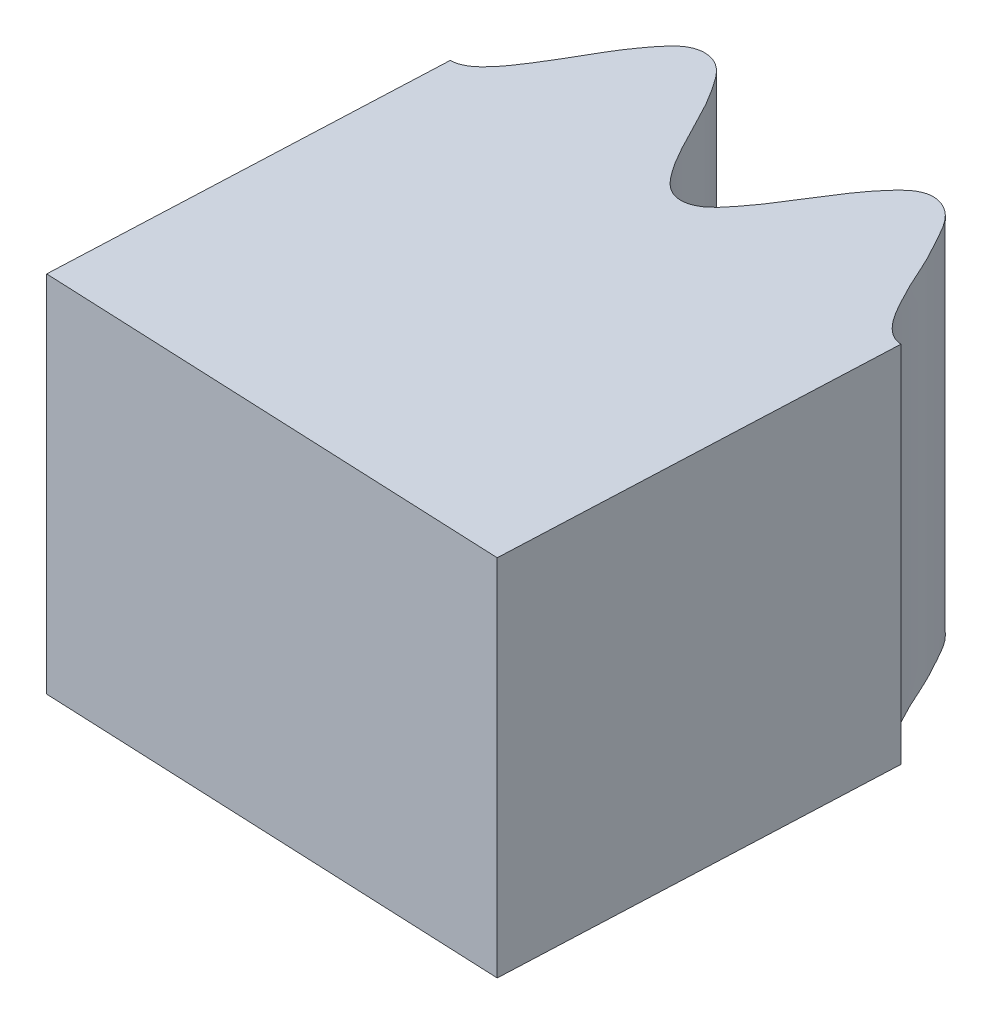
from build123d import *

# Parameters (mm, degrees)
BOSS_EXTRUDE1_DEPTH     = 4
CUT_EXTRUDE1_DEPTH      = 108.175858735
CUT_EXTRUDE1_DEPTH_BACK = 108.175858735
CUT_EXTRUDE2_DEPTH      = 108.175858735
CUT_EXTRUDE2_DEPTH_BACK = 108.175858735
BOSS_EXTRUDE2_DEPTH     = 4


with BuildPart() as part:
    # Sketch1 → Boss-Extrude1 (new body)
    with BuildSketch(Plane(origin=(0, 0, 0), x_dir=(1, 0, 0), z_dir=(0, 1, 0))):
        with BuildLine():
            Line((0, 75), (0, 70))
            ThreePointArc((0, 70), (49.497474683, 49.497474683), (70, 0))
            Line((70, 0), (75, 0))
            add(Edge.make_bspline(
                [(75, 0), (75.050380079, 0.027988933), (75.150135116, 0.083928974), (75.385849219, 0.218346892), (75.556555779, 0.343302659), (75.793115459, 0.559091771), (75.726722821, 0.834487841), (75.524960142, 0.992415461), (75.335000623, 1.121349717), (75.126464936, 1.235293314), (74.920161758, 1.346137726), (74.711717083, 1.454249545), (74.512091935, 1.582315518), (74.31519481, 1.710306134), (74.163925882, 1.951349773), (74.330026374, 2.215393011), (74.573477976, 2.375635279), (74.836790459, 2.557091933), (75.141374934, 2.718012309), (75.389801527, 2.903502283), (75.648009918, 3.082166594), (75.723439753, 3.396877772), (75.484714529, 3.607987744), (75.257107431, 3.741829311), (75.004765702, 3.881288724), (74.700478181, 4.006189191), (74.467832583, 4.166559633), (74.081283762, 4.334614415), (74.09284664, 4.763739624), (74.445000666, 4.953113102), (74.663168002, 5.151438188), (74.94910869, 5.304380051), (75.178477729, 5.481747085), (75.393823876, 5.637930813), (75.582039215, 5.900063188), (75.423263936, 6.184063895), (75.153916827, 6.321420138), (74.878763729, 6.475334049), (74.5559891, 6.595691699), (74.279522738, 6.747645077), (74.008187432, 6.878454168), (73.839963794, 7.158428572), (74.030263913, 7.423041671), (74.237833878, 7.581836742), (74.470150707, 7.766479023), (74.737154867, 7.928082807), (74.970020459, 8.1380106), (75.252496752, 8.326816283), (75.307893073, 8.683144239), (75.032251257, 8.866746013), (74.82784501, 8.980258245), (74.580383895, 9.083638758), (74.349881421, 9.178011902), (74.104661365, 9.274265746), (73.887987065, 9.389698553), (73.645710544, 9.521815238), (73.566612993, 9.80014415), (73.759151351, 10.018596352), (73.934367827, 10.182293625), (74.145907118, 10.343780146), (74.341023974, 10.49346119), (74.561479221, 10.654271157), (74.72121168, 10.816376575), (74.989223643, 11.059535394), (74.862651988, 11.461920806), (74.451242671, 11.561758423), (74.15694857, 11.722473713), (73.81648944, 11.813693993), (73.579175892, 11.938444947), (73.300383285, 12.049406982), (73.16438962, 12.33940789), (73.364023484, 12.589425786), (73.543848199, 12.763957193), (73.760572421, 12.94384802), (73.966599088, 13.108018933), (74.180853477, 13.288597269), (74.360831943, 13.46820344), (74.539613211, 13.708707239), (74.43371274, 13.973785573), (74.203670067, 14.090873366), (73.996553795, 14.186713105), (73.770279808, 14.261834472), (73.548334678, 14.335540611), (73.324103361, 14.405672823), (73.105333431, 14.497176402), (72.88918309, 14.589016669), (72.698363493, 14.800137022), (72.816085622, 15.089008525), (73.028015684, 15.289093489), (73.255816396, 15.513515693), (73.527831137, 15.724882744), (73.740272942, 15.950693037), (73.96353415, 16.171480699), (73.983168867, 16.494508845), (73.711411643, 16.660957453), (73.464021005, 16.753242061), (73.191296074, 16.846764116), (72.869942608, 16.916928077), (72.612983394, 17.034463655), (72.203124707, 17.132841805), (72.13999511, 17.557455513), (72.453914764, 17.805102886), (72.63432886, 18.038299329), (72.88936739, 18.238570741), (73.084452336, 18.453072687), (73.269405871, 18.644278099), (73.409242987, 18.935111345), (73.203563656, 19.187226405), (72.914456873, 19.275724264), (72.616757098, 19.379520042), (72.277986255, 19.441999963), (71.979333611, 19.543636947), (71.689405738, 19.625341873), (71.47512075, 19.871851109), (71.6165802, 20.165489409), (71.793422236, 20.357916172), (71.990146855, 20.580094717), (72.225032419, 20.785608162), (72.417906681, 21.032783366), (72.663305761, 21.26777216), (72.655984788, 21.628306163), (72.352648477, 21.761253914), (72.131636428, 21.837546868), (71.869982965, 21.896385627), (71.626594617, 21.949298697), (71.368385701, 22.001508213), (71.134958474, 22.077562239), (70.873420856, 22.165600898), (70.747193666, 22.425966223), (70.898873107, 22.67453358), (71.043001918, 22.866169945), (71.223285612, 23.061936536), (71.389446363, 23.243225275), (71.578628043, 23.439873829), (71.707784496, 23.627253752), (71.929500669, 23.913258231), (71.734978429, 24.287551568), (71.312482723, 24.314431948), (70.994751694, 24.421601978), (70.643624667, 24.452316309), (70.388253669, 24.533962951), (70.094428194, 24.594827395), (69.910142448, 24.856807486), (70.063328273, 25.137693104), (70.210113987, 25.340799221), (70.392307966, 25.555590868), (70.566696646, 25.753043812), (70.74633893, 25.968083641), (70.892394834, 26.176214124), (71.026696966, 26.444109171), (70.876374992, 26.686770946), (70.629495102, 26.76213342), (70.408882995, 26.820551776), (70.173001931, 26.855239815), (69.941629709, 26.889285824), (69.708626639, 26.919415211), (69.477290886, 26.971539645), (69.248476459, 27.024450539), (69.023895176, 27.199228025), (69.089666831, 27.504153154), (69.26363281, 27.737999647), (69.449002211, 27.998569552), (69.680180933, 28.253960326), (69.850183724, 28.513230186), (70.031713718, 28.769432489), (69.99495689, 29.090962644), (69.698424772, 29.207692377), (69.438767499, 29.255616041), (69.153945938, 29.300359099), (68.82529071, 29.313654668), (68.551825444, 29.384784117), (68.131110245, 29.410496468), (67.995206332, 29.817697), (68.261353327, 30.116093629), (68.398532389, 30.377075873), (68.614919545, 30.618591688), (68.769792841, 30.863711013), (68.918734044, 31.084128429), (69.005944057, 31.394825725), (68.759610136, 31.60739475), (68.459528044, 31.644345262), (68.14832705, 31.694869125), (67.803853373, 31.697572897), (67.492088856, 31.745805299), (67.192377728, 31.775923497), (66.93854233, 31.981477506), (67.026862937, 32.295218956), (67.167603789, 32.515430621), (67.32275882, 32.768394646), (67.518388909, 33.01157333), (67.665411453, 33.288485652), (67.866276995, 33.562517541), (67.79646117, 33.916302949), (67.474647085, 33.994557128), (67.243744573, 34.03131268), (66.975848971, 34.0438219), (66.726969981, 34.053667158), (66.463617751, 34.060245986), (66.220530165, 34.094610368), (65.947678138, 34.135895991), (65.778156659, 34.37038666), (65.88436848, 34.641516579), (65.993030345, 34.855269263), (66.136580612, 35.079367654), (66.26873655, 35.286755721), (66.420896471, 35.513267796), (66.515552566, 35.720228779), (66.684236215, 36.040388818), (66.427673849, 36.375217365), (66.006929074, 36.328323763), (65.675415212, 36.378692224), (65.324289106, 36.347967367), (65.058619977, 36.384028905), (64.758689371, 36.392946423), (64.531710975, 36.618945564), (64.633794287, 36.922164338), (64.743080989, 37.147673888), (64.885208854, 37.39084002), (65.022660834, 37.615575486), (65.162232674, 37.858542932), (65.269928182, 38.088873787), (65.355670476, 38.376020227), (65.165494455, 38.588892287), (64.909278669, 38.620239594), (64.681873915, 38.639461552), (64.443552899, 38.632662285), (64.209783714, 38.626013695), (63.975088571, 38.61522479), (63.738216014, 38.626386305), (63.503689913, 38.638760155), (63.252170732, 38.771884247), (63.263993475, 39.083598007), (63.394709502, 39.344100721), (63.532015236, 39.632901042), (63.715333692, 39.924555621), (63.83773202, 40.209407264), (63.972015102, 40.493239631), (63.879983568, 40.803502265), (63.567686533, 40.866966348), (63.30365218, 40.869072932), (63.015388149, 40.863677497), (62.68941718, 40.819700696), (62.407754967, 40.842262783), (61.988966475, 40.794528078), (61.784417618, 41.171942853), (61.99470521, 41.512022106), (62.084481123, 41.792860338), (62.255642091, 42.06828222), (62.365597989, 42.336571098), (62.474001359, 42.579503247), (62.505934436, 42.900624212), (62.226430657, 43.0671884), (61.924491097, 43.051468841), (61.609244568, 43.047185648), (61.269534715, 42.990031117), (60.954131133, 42.983393421), (60.653743321, 42.961009764), (60.368070174, 43.119362892), (60.400568362, 43.443674617), (60.500931689, 43.684980165), (60.609802825, 43.961043486), (60.760233318, 44.234498548), (60.856936939, 44.532734146), (61.007165744, 44.83748281), (60.876976387, 45.173770032), (60.546462685, 45.194952924), (60.312685567, 45.191054278), (60.046687698, 45.15685387), (59.799880128, 45.123332174), (59.539386408, 45.08408042), (59.294024556, 45.075711013), (59.018148592, 45.068989158), (58.810483647, 45.270480291), (58.868000656, 45.555934626), (58.937893939, 45.785308862), (59.040349078, 46.030929937), (59.13448471, 46.258115951), (59.244999571, 46.507609091), (59.302279229, 46.727862731), (59.412804987, 47.072450427), (59.101998013, 47.357640589), (58.695788285, 47.238397843), (58.360564473, 47.230434316), (58.020108077, 47.13920383), (57.752213038, 47.128584552), (57.455290541, 47.08528419), (57.192516118, 47.268435511), (57.240395168, 47.584774291), (57.308862236, 47.825835282), (57.406605504, 48.089987418), (57.502944375, 48.335176934), (57.598204951, 48.598689554), (57.664267789, 48.844222294), (57.698845009, 49.141895328), (57.474593344, 49.318509663), (57.216826649, 49.304889329), (56.989538826, 49.284330842), (56.756019122, 49.236250861), (56.526955932, 49.189109685), (56.297699809, 49.137730304), (56.062487702, 49.107589762), (55.829375882, 49.079050596), (55.558561088, 49.166476387), (55.51607569, 49.475507512), (55.599570026, 49.754751204), (55.684640127, 50.06300689), (55.814528278, 50.382063496), (55.885603131, 50.683841849), (55.968559178, 50.986680177), (55.824049269, 51.276248116), (55.505476305, 51.284518227), (55.245087423, 51.240743723), (54.962139678, 51.185373733), (54.648757432, 51.085460773), (54.367456436, 51.058769962), (53.963319326, 50.939038596), (53.696340638, 51.275200055), (53.844379347, 51.646628798), (53.884024315, 51.93878989), (54.004758455, 52.239749285), (54.066456001, 52.523055893), (54.131027755, 52.781121404), (54.106713627, 53.102908941), (53.802532571, 53.218407323), (53.507909823, 53.150495326), (53.198196367, 53.091535218), (52.87357225, 52.976258997), (52.564112981, 52.914952884), (52.272175616, 52.84074749), (51.963344753, 52.947088254), (51.939033082, 53.272116211), (51.995969392, 53.527183684), (52.055248646, 53.817958278), (52.155908772, 54.113380885), (52.199355211, 54.423878093), (52.294382606, 54.75008379), (52.107775521, 55.058655064), (51.778604574, 55.022122758), (51.549056364, 54.977689105), (51.293037634, 54.897816359), (51.055802482, 54.821950619), (50.806078132, 54.738051344), (50.56590552, 54.687221821), (50.295372778, 54.632661313), (50.055902112, 54.795095863), (50.062915856, 55.08605942), (50.09207674, 55.324458468), (50.149925898, 55.583211719), (50.204091553, 55.825415688), (50.267685365, 56.08583746), (50.289340345, 56.320833048), (50.33220459, 56.665051109), (50.043864784, 56.879773011), (49.725988748, 56.758235804), (49.458556625, 56.70381228), (49.208859877, 56.602430564), (48.958192708, 56.510209672), (48.688345013, 56.434892178), (48.407243163, 56.349527164), (48.114974261, 56.48034264), (48.108115299, 56.802336912), (48.13315996, 57.050406823), (48.183821075, 57.328153727), (48.235988604, 57.586041862), (48.284103231, 57.862232281), (48.306500727, 58.115447335), (48.288872371, 58.414625886), (48.037354269, 58.549605515), (47.785871198, 58.491437036), (47.565604998, 58.431719652), (47.343982615, 58.343821314), (47.126585124, 58.257619294), (46.909733953, 58.167210809), (46.683329063, 58.096683937), (46.45871452, 58.028098927), (46.176832677, 58.067170017), (46.081330039, 58.364128759), (46.115065748, 58.653628748), (46.145315407, 58.971973608), (46.217826665, 59.308737866), (46.235418471, 59.618273548), (46.264526906, 59.930916246), (46.071929482, 60.190991116), (45.756760267, 60.14381597), (45.507928641, 60.055490445), (45.238894405, 59.951828289), (44.947622843, 59.799014975), (44.675230252, 59.723882252), (44.298024026, 59.535792202), (43.976727519, 59.820486251), (44.058019263, 60.211978809), (44.046328694, 60.506585594), (44.112967561, 60.823938002), (44.124532107, 61.113654213), (44.143310265, 61.379011896), (44.063487703, 61.691688654), (43.743871757, 61.752611869), (43.465517786, 61.634570905), (43.170747888, 61.522725356), (42.871073047, 61.352830054), (42.576960853, 61.238718279), (42.302344305, 61.114945843), (41.979739396, 61.166043132), (41.899356564, 61.481911513), (41.911135875, 61.742990809), (41.919022081, 62.039641651), (41.966853329, 62.348055511), (41.955722493, 62.661380074), (41.992661108, 62.999131137), (41.755306272, 63.270610783), (41.437479747, 63.177473111), (41.21913522, 63.093855031), (40.98087445, 62.970735598), (40.760420405, 62.854833848), (40.529052255, 62.72882995), (40.30136826, 62.637097556), (40.044395352, 62.536332758), (39.780401399, 62.65481835), (39.736685168, 62.942356463), (39.724263543, 63.182783839), (39.735658003, 63.446188529), (39.748425967, 63.697489546), (39.762655618, 63.957780496), (39.749210432, 64.206680433), (39.725416869, 64.467041136), (39.536087518, 64.660427871), (39.277015035, 64.613902502), (39.074812109, 64.531265857), (38.854985285, 64.417855901), (38.635555446, 64.29480726), (38.399826184, 64.149361027), (38.149659321, 64.034015597), (37.886507528, 63.898535171), (37.576462819, 63.977747086), (37.513522678, 64.293041196), (37.4952636, 64.542040428), (37.496844849, 64.824183237), (37.503476484, 65.087299643), (37.502882645, 65.367609285), (37.480976988, 65.620883641), (37.41166167, 65.912449127), (37.140527066, 66.001705495), (36.902964728, 65.900749534), (36.696415072, 65.803691456), (36.493422833, 65.678643748), (36.294296999, 65.556000829), (36.096439524, 65.429309974), (35.885721106, 65.32053979), (35.676428622, 65.213992827), (35.392044574, 65.203522074), (35.246426491, 65.479385485), (35.229378534, 65.770345464), (35.203888627, 66.089106747), (35.216819777, 66.433346248), (35.180394017, 66.741234172), (35.154770394, 67.054181752), (34.919937431, 67.276861308), (34.617748223, 67.1756743), (34.388034474, 67.045481479), (34.141088217, 66.896676879), (33.880777479, 66.695606367), (33.625569803, 66.574314602), (33.286755682, 66.323580888), (32.920903788, 66.548157242), (32.932978559, 66.947818312), (32.870307664, 67.235919312), (32.88082647, 67.560022142), (32.841906632, 67.847345074), (32.814320629, 68.111932171), (32.681415003, 68.405997624), (32.356075536, 68.410494553), (32.102447986, 68.245911235), (31.83157808, 68.084578617), (31.565957983, 67.865226415), (31.296129317, 67.70177621), (31.047177668, 67.532197488), (30.720600902, 67.526498746), (30.586589296, 67.823610033), (30.552853713, 68.082768431), (30.509107222, 68.376281848), (30.502656319, 68.688316125), (30.437286313, 68.99494754), (30.415013942, 69.333982027), (30.134123041, 69.560120626), (29.837298333, 69.413208698), (29.636790733, 69.292943812), (29.423530024, 69.130326456), (29.226549247, 68.97789203), (29.020580945, 68.813652154), (28.812276052, 68.683723109), (28.576721385, 68.53996383), (28.296132702, 68.610627797), (28.203216725, 68.886597007), (28.149058966, 69.120187564), (28.114977181, 69.384129224), (28.082908023, 69.6279459), (28.05387013, 69.899270728), (27.993348949, 70.118655804), (27.916773216, 70.472340382), (27.5050114, 70.56391882), (27.212844829, 70.257546708), (26.926514255, 70.083038186), (26.67728561, 69.83380207), (26.45059134, 69.690657985), (26.215099096, 69.504697523), (25.895954109, 69.531924008), (25.779249192, 69.829820953), (25.718012918, 70.072819429), (25.670585003, 70.350453524), (25.631422155, 70.610963309), (25.582163923, 70.88680222), (25.516609649, 71.132471229), (25.397717883, 71.407552249), (25.115203076, 71.448378917), (24.898780737, 71.307700015), (24.712222952, 71.176251931), (24.534028947, 71.017853594), (24.359224993, 70.862496543), (24.186373057, 70.703372632), (23.997743668, 70.559664104), (23.810132494, 70.418392551), (23.531887106, 70.358698109), (23.34057811, 70.605084216), (23.27326448, 70.888663515), (23.192809506, 71.19815582), (23.145767641, 71.539411021), (23.056431093, 71.836296169), (22.976853973, 72.140039877), (22.706920751, 72.318558114), (22.426893416, 72.166433758), (22.223277282, 71.998329485), (22.005922341, 71.808903794), (21.784481835, 71.56568551), (21.554213432, 71.401920091), (21.264086111, 71.096161131), (20.864795055, 71.253796151), (20.807285966, 71.649482233), (20.69553897, 71.922323644), (20.649618105, 72.243329196), (20.561396443, 72.519528688), (20.488284467, 72.775305854), (20.306334046, 73.041824972), (19.985156333, 72.989758976), (19.763961548, 72.783634087), (19.52522188, 72.577716409), (19.301727259, 72.315572213), (19.064380727, 72.107749928), (18.848658249, 71.897517488), (18.528032494, 71.835195863), (18.344463992, 72.10452249), (18.266238545, 72.353885567), (18.172188591, 72.635343357), (18.111651508, 72.941516945), (17.994028633, 73.232138557), (17.913221909, 73.562154792), (17.597329816, 73.736081645), (17.330525531, 73.539858569), (17.15394787, 73.386602997), (16.972165278, 73.189423831), (16.804647042, 73.005099874), (16.630327816, 72.80758915), (16.447749484, 72.643462255), (16.24073696, 72.460983363), (15.95214038, 72.481850072), (15.812714454, 72.737492), (15.718816899, 72.958129395), (15.639419905, 73.212142949), (15.565499628, 73.44668675), (15.489787824, 73.708847167), (15.392090277, 73.914389898), (15.255261219, 74.249403976), (14.833852561, 74.268089443), (14.599325616, 73.91563762), (14.347648133, 73.694059491), (14.145485229, 73.405331732), (13.947091664, 73.224997281), (13.747468771, 73.000969177), (13.428444485, 72.972363085), (13.261783316, 73.24546871), (13.159281115, 73.474141926), (13.064363082, 73.739322364), (12.980558157, 73.989073862), (12.884149344, 74.252168559), (12.776931011, 74.482721923), (12.612078161, 74.732978505), (12.326765912, 74.724126744), (12.138060149, 74.548003725), (11.977162316, 74.386157214), (11.829181061, 74.199222239), (11.684010241, 74.015871023), (11.541415892, 73.829149138), (11.380606931, 73.654868716), (11.220377539, 73.483165057), (10.956725155, 73.376060703), (10.725538075, 73.585483192), (10.610004061, 73.853065395), (10.477028604, 74.143884958), (10.371443067, 74.471786991), (10.231910177, 74.748648657), (10.100797471, 75.033959394), (9.803965775, 75.162892126), (9.554608801, 74.964452645), (9.383277054, 74.763544682), (9.202117649, 74.539253504), (9.026275734, 74.261277511), (8.827943192, 74.060014369), (8.595318043, 73.708520494), (8.174720081, 73.79442452), (8.049374518, 74.174112892), (7.891946796, 74.423404568), (7.790981543, 74.731559249), (7.656138628, 74.98824312), (7.539722148, 75.227438694), (7.314255404, 75.458313428), (7.006998267, 75.351266508), (6.824957139, 75.109863048), (6.625601693, 74.865617013), (6.451023319, 74.568645944), (6.253370576, 74.322766152), (6.077431887, 74.078267803), (5.772499195, 73.9612169), (5.54495143, 74.194575524), (5.424612966, 74.426566488), (5.283117197, 74.687416743), (5.170333346, 74.978426629), (5.004031473, 75.244208198), (4.867145729, 75.555178575), (4.525850576, 75.671609329), (4.297173589, 75.432036653), (4.149890663, 75.250448544), (4.005110652, 75.024694787), (3.872142368, 74.814091142), (3.734774401, 74.589290548), (3.5834589, 74.395993722), (3.41129911, 74.18026478), (3.123425549, 74.150838141), (2.941808652, 74.378085029), (2.810807208, 74.579854394), (2.689048386, 74.81425693), (2.574280945, 75.036906087), (2.456832031, 75.272410252), (2.320029139, 75.475394151), (2.159305224, 75.715332045), (1.844035288, 75.763483705), (1.634313572, 75.499980528), (1.47304379, 75.277275417), (1.32422083, 75.014662596), (1.195027528, 74.788052405), (1.052689935, 74.564712631), (0.920118974, 74.378992231), (0.710817146, 74.201954221), (0.456909161, 74.28184324), (0.30476885, 74.498176728), (0.185042825, 74.663213522), (0.074352375, 74.865858994), (0.024779937, 74.955396113), (0, 75)],
                knots=[0.075900432, 0.075900432, 0.075900432, 0.075900432, 0.075900432, 0.077143219, 0.078386005, 0.079628792, 0.080871578, 0.081946406, 0.083021233, 0.08409606, 0.085170887, 0.086245458, 0.087320029, 0.088394601, 0.089469172, 0.090645937, 0.091822703, 0.093374384, 0.094926065, 0.096477746, 0.098029428, 0.099205995, 0.100382563, 0.101707425, 0.103032287, 0.104357149, 0.105682011, 0.10733155, 0.108981089, 0.110629316, 0.112277542, 0.113603053, 0.114928563, 0.116254074, 0.117579584, 0.118755852, 0.11993212, 0.12148425, 0.12303638, 0.124588511, 0.126140641, 0.12731548, 0.128490319, 0.129816645, 0.131142972, 0.132469298, 0.133795624, 0.135443357, 0.137091089, 0.138262925, 0.13943476, 0.140606595, 0.141778431, 0.142949907, 0.144121384, 0.145292861, 0.146464337, 0.147635476, 0.148806615, 0.149977754, 0.151148893, 0.152319617, 0.153490341, 0.154661065, 0.155831789, 0.157914479, 0.15999717, 0.161299161, 0.162601152, 0.163903143, 0.165205135, 0.166443951, 0.167682767, 0.168921584, 0.1701604, 0.171399276, 0.172638153, 0.173877029, 0.175115905, 0.176190732, 0.177265559, 0.178340387, 0.179415214, 0.180489785, 0.181564356, 0.182638927, 0.183713499, 0.184890264, 0.18606703, 0.187618711, 0.189170392, 0.190722073, 0.192273754, 0.193450322, 0.19462689, 0.195951752, 0.197276614, 0.198601476, 0.199926338, 0.201575877, 0.203225416, 0.204873642, 0.206521869, 0.207847379, 0.20917289, 0.2104984, 0.211823911, 0.213000179, 0.214176447, 0.215728577, 0.217280707, 0.218832837, 0.220384968, 0.221559807, 0.222734645, 0.224060972, 0.225387298, 0.226713625, 0.228039951, 0.229687684, 0.231335416, 0.232507252, 0.233679087, 0.234850922, 0.236022758, 0.237194234, 0.238365711, 0.239537188, 0.240708664, 0.241879803, 0.243050942, 0.244222081, 0.24539322, 0.246563944, 0.247734668, 0.248905392, 0.250076115, 0.252158806, 0.254241497, 0.255543488, 0.256845479, 0.25814747, 0.259449461, 0.260688278, 0.261927094, 0.26316591, 0.264404727, 0.265643603, 0.266882479, 0.268121356, 0.269360232, 0.270435059, 0.271509886, 0.272584713, 0.273659541, 0.274734112, 0.275808683, 0.276883254, 0.277957825, 0.279134591, 0.280311356, 0.281863038, 0.283414719, 0.2849664, 0.286518081, 0.287694649, 0.288871217, 0.290196078, 0.29152094, 0.292845802, 0.294170664, 0.295820204, 0.297469743, 0.299117969, 0.300766196, 0.302091706, 0.303417217, 0.304742727, 0.306068238, 0.307244506, 0.308420773, 0.309972904, 0.311525034, 0.313077164, 0.314629294, 0.315804133, 0.316978972, 0.318305299, 0.319631625, 0.320957951, 0.322284278, 0.32393201, 0.325579743, 0.326751578, 0.327923414, 0.329095249, 0.330267084, 0.331438561, 0.332610038, 0.333781514, 0.334952991, 0.33612413, 0.337295269, 0.338466408, 0.339637547, 0.340808271, 0.341978995, 0.343149718, 0.344320442, 0.346403133, 0.348485823, 0.349787815, 0.351089806, 0.352391797, 0.353693788, 0.354932604, 0.356171421, 0.357410237, 0.358649053, 0.35988793, 0.361126806, 0.362365682, 0.363604559, 0.364679386, 0.365754213, 0.36682904, 0.367903867, 0.368978439, 0.37005301, 0.371127581, 0.372202152, 0.373378918, 0.374555683, 0.376107364, 0.377659046, 0.379210727, 0.380762408, 0.381938976, 0.383115543, 0.384440405, 0.385765267, 0.387090129, 0.388414991, 0.39006453, 0.391714069, 0.393362296, 0.395010522, 0.396336033, 0.397661543, 0.398987054, 0.400312564, 0.401488832, 0.4026651, 0.40421723, 0.405769361, 0.407321491, 0.408873621, 0.41004846, 0.411223299, 0.412549625, 0.413875952, 0.415202278, 0.416528605, 0.418176337, 0.41982407, 0.420995905, 0.42216774, 0.423339576, 0.424511411, 0.425682888, 0.426854364, 0.428025841, 0.429197318, 0.430368457, 0.431539596, 0.432710735, 0.433881874, 0.435052597, 0.436223321, 0.437394045, 0.438564769, 0.44064746, 0.44273015, 0.444032141, 0.445334132, 0.446636124, 0.447938115, 0.449176931, 0.450415748, 0.451654564, 0.45289338, 0.454132256, 0.455371133, 0.456610009, 0.457848885, 0.458923713, 0.45999854, 0.461073367, 0.462148194, 0.463222765, 0.464297337, 0.465371908, 0.466446479, 0.467623244, 0.46880001, 0.470351691, 0.471903372, 0.473455053, 0.475006735, 0.476183302, 0.47735987, 0.478684732, 0.480009594, 0.481334456, 0.482659318, 0.484308857, 0.485958396, 0.487606623, 0.489254849, 0.49058036, 0.49190587, 0.493231381, 0.494556891, 0.495733159, 0.496909427, 0.498461557, 0.500013687, 0.501565818, 0.503117948, 0.504292787, 0.505467626, 0.506793952, 0.508120279, 0.509446605, 0.510772931, 0.512420664, 0.514068396, 0.515240232, 0.516412067, 0.517583902, 0.518755738, 0.519927214, 0.521098691, 0.522270168, 0.523441644, 0.524612783, 0.525783922, 0.526955061, 0.5281262, 0.529296924, 0.530467648, 0.531638372, 0.532809096, 0.534891786, 0.535933132, 0.536974477, 0.538276468, 0.539578459, 0.54088045, 0.542182442, 0.543421258, 0.544660074, 0.545898891, 0.547137707, 0.548376583, 0.54961546, 0.550854336, 0.552093212, 0.553168039, 0.554242867, 0.555317694, 0.556392521, 0.557467092, 0.558541663, 0.559616234, 0.560690806, 0.561867571, 0.563044337, 0.564596018, 0.566147699, 0.56769938, 0.569251061, 0.570427629, 0.571604197, 0.572929059, 0.574253921, 0.575578783, 0.576903645, 0.578553184, 0.580202723, 0.581850949, 0.583499176, 0.584824686, 0.586150197, 0.587475707, 0.588801218, 0.589977486, 0.591153754, 0.592705884, 0.594258014, 0.595810144, 0.597362275, 0.598537114, 0.599711952, 0.601038279, 0.602364605, 0.603690932, 0.605017258, 0.606664991, 0.608312723, 0.609484559, 0.610656394, 0.611828229, 0.613000065, 0.614171541, 0.615343018, 0.616514495, 0.617685971, 0.61885711, 0.620028249, 0.621199388, 0.622370527, 0.623541251, 0.624711975, 0.625882699, 0.627053422, 0.628094768, 0.629136113, 0.630177458, 0.631218804, 0.632520795, 0.633822786, 0.635124777, 0.636426768, 0.637665585, 0.638904401, 0.640143217, 0.641382034, 0.64262091, 0.643859786, 0.645098663, 0.646337539, 0.647412366, 0.648487193, 0.64956202, 0.650636848, 0.651711419, 0.65278599, 0.653860561, 0.654935132, 0.656111898, 0.657288663, 0.658840345, 0.660392026, 0.661943707, 0.663495388, 0.664671956, 0.665848524, 0.667173386, 0.668498247, 0.669823109, 0.671147971, 0.672797511, 0.67444705, 0.676095276, 0.677743503, 0.679069013, 0.680394524, 0.681720034, 0.683045545, 0.684221813, 0.68539808, 0.686950211, 0.688502341, 0.690054471, 0.691606601, 0.69278144, 0.693956279, 0.695282606, 0.696608932, 0.697935258, 0.699261585, 0.700909317, 0.70255705, 0.703728885, 0.704900721, 0.706072556, 0.707244391, 0.708415868, 0.709587345, 0.710758821, 0.711930298, 0.713101437, 0.714272576, 0.715443715, 0.716614854, 0.717785578, 0.718956302, 0.720127025, 0.721297749, 0.72338044, 0.72546313, 0.726765122, 0.728067113, 0.729369104, 0.730671095, 0.731909911, 0.733148728, 0.734387544, 0.73562636, 0.736865237, 0.738104113, 0.739342989, 0.740581866, 0.741656693, 0.74273152, 0.743806347, 0.744881174, 0.745955746, 0.747030317, 0.748104888, 0.749179459, 0.750356225, 0.75153299, 0.753084671, 0.754636353, 0.756188034, 0.757739715, 0.758916283, 0.76009285, 0.761417712, 0.762742574, 0.764067436, 0.765392298, 0.767041837, 0.768691376, 0.770339603, 0.771987829, 0.77331334, 0.774638851, 0.775964361, 0.777289872, 0.778466139, 0.779642407, 0.781194537, 0.782746668, 0.784298798, 0.785850928, 0.787025767, 0.788200606, 0.789526932, 0.790853259, 0.792179585, 0.793505912, 0.795153644, 0.796801377, 0.797973212, 0.799145047, 0.800316883, 0.801488718, 0.802660195, 0.803831671, 0.805003148, 0.806174625, 0.807345764, 0.808516903, 0.809688042, 0.810859181, 0.812029905, 0.813200628, 0.814371352, 0.815542076, 0.817624767, 0.819707457, 0.821009448, 0.822311439, 0.823613431, 0.824915422, 0.826154238, 0.827393055, 0.828631871, 0.829870687, 0.831109563, 0.83234844, 0.833587316, 0.834826192, 0.83590102, 0.836975847, 0.838050674, 0.839125501, 0.840200072, 0.841274644, 0.842349215, 0.843423786, 0.844600551, 0.845777317, 0.847328998, 0.848880679, 0.85043236, 0.851984042, 0.853160609, 0.854337177, 0.855662039, 0.856986901, 0.858311763, 0.859636625, 0.861286164, 0.862935703, 0.86458393, 0.866232156, 0.867557667, 0.868883177, 0.870208688, 0.871534198, 0.872710466, 0.873886734, 0.875438864, 0.876990994, 0.878543125, 0.880095255, 0.881270094, 0.882444933, 0.883771259, 0.885097586, 0.886423912, 0.887750238, 0.889397971, 0.891045703, 0.892217539, 0.893389374, 0.894561209, 0.895733045, 0.896904522, 0.898075998, 0.899247475, 0.900418952, 0.90159009, 0.902761229, 0.903932368, 0.905103507, 0.906274231, 0.907444955, 0.908615679, 0.909786403, 0.911163858, 0.912541313, 0.913918769, 0.915296224, 0.916396795, 0.917497367, 0.918597938, 0.91969851, 0.920798808, 0.921899106, 0.922999405, 0.924099703, 0.924099703, 0.924099703, 0.924099703, 0.924099703], degree=4))
        make_face()
    extrude(amount=BOSS_EXTRUDE1_DEPTH)

    # Sketch2 → Cut-Extrude1 (cut, two sides)
    with BuildSketch(Plane(origin=(0, 4, 0), x_dir=(1, 0, 0), z_dir=(0, 1, 0))) as cut_extrude1_sk:
        with BuildLine():
            Line((0.462356885, 69.998473027), (0.647966779, 74.249638519))
            add(Edge.make_bspline(
                [(0.647966779, 74.249638519), (0.632487966, 74.249924606), (0.558764992, 74.257351103), (0.42900569, 74.321520135), (0.30476885, 74.498176728), (0.185042825, 74.663213522), (0.074352375, 74.865858994), (0.024779937, 74.955396113), (0, 75)],
                knots=[0.919405194, 0.919405194, 0.919405194, 0.919405194, 0.919405194, 0.91969851, 0.920798808, 0.921899106, 0.922999405, 0.924099703, 0.924099703, 0.924099703, 0.924099703, 0.924099703], degree=4))
            Line((0, 75), (0, 70))
            ThreePointArc((0, 70), (0.231179703, 69.999618256), (0.462356885, 69.998473027))
        make_face()
    extrude(amount=CUT_EXTRUDE1_DEPTH, mode=Mode.SUBTRACT)
    extrude(cut_extrude1_sk.sketch, amount=-CUT_EXTRUDE1_DEPTH_BACK, mode=Mode.SUBTRACT)

    # Sketch3 → Cut-Extrude2 (cut, two sides)
    with BuildSketch(Plane(origin=(0, 4, 0), x_dir=(1, 0, 0), z_dir=(0, 1, 0))) as cut_extrude2_sk:
        with BuildLine():
            Line((5.825797701, 74.023778337), (5.640178696, 69.772404174))
            ThreePointArc((5.640178696, 69.772404174), (51.452951853, 47.461497507), (70, 0))
            Line((70, 0), (75, 0))
            add(Edge.make_bspline(
                [(75, 0), (75.050380079, 0.027988933), (75.150135116, 0.083928974), (75.385849219, 0.218346892), (75.556555779, 0.343302659), (75.793115459, 0.559091771), (75.726722821, 0.834487841), (75.524960142, 0.992415461), (75.335000623, 1.121349717), (75.126464936, 1.235293314), (74.920161758, 1.346137726), (74.711717083, 1.454249545), (74.512091935, 1.582315518), (74.31519481, 1.710306134), (74.163925882, 1.951349773), (74.330026374, 2.215393011), (74.573477976, 2.375635279), (74.836790459, 2.557091933), (75.141374934, 2.718012309), (75.389801527, 2.903502283), (75.648009918, 3.082166594), (75.723439753, 3.396877772), (75.484714529, 3.607987744), (75.257107431, 3.741829311), (75.004765702, 3.881288724), (74.700478181, 4.006189191), (74.467832583, 4.166559633), (74.081283762, 4.334614415), (74.09284664, 4.763739624), (74.445000666, 4.953113102), (74.663168002, 5.151438188), (74.94910869, 5.304380051), (75.178477729, 5.481747085), (75.393823876, 5.637930813), (75.582039215, 5.900063188), (75.423263936, 6.184063895), (75.153916827, 6.321420138), (74.878763729, 6.475334049), (74.5559891, 6.595691699), (74.279522738, 6.747645077), (74.008187432, 6.878454168), (73.839963794, 7.158428572), (74.030263913, 7.423041671), (74.237833878, 7.581836742), (74.470150707, 7.766479023), (74.737154867, 7.928082807), (74.970020459, 8.1380106), (75.252496752, 8.326816283), (75.307893073, 8.683144239), (75.032251257, 8.866746013), (74.82784501, 8.980258245), (74.580383895, 9.083638758), (74.349881421, 9.178011902), (74.104661365, 9.274265746), (73.887987065, 9.389698553), (73.645710544, 9.521815238), (73.566612993, 9.80014415), (73.759151351, 10.018596352), (73.934367827, 10.182293625), (74.145907118, 10.343780146), (74.341023974, 10.49346119), (74.561479221, 10.654271157), (74.72121168, 10.816376575), (74.989223643, 11.059535394), (74.862651988, 11.461920806), (74.451242671, 11.561758423), (74.15694857, 11.722473713), (73.81648944, 11.813693993), (73.579175892, 11.938444947), (73.300383285, 12.049406982), (73.16438962, 12.33940789), (73.364023484, 12.589425786), (73.543848199, 12.763957193), (73.760572421, 12.94384802), (73.966599088, 13.108018933), (74.180853477, 13.288597269), (74.360831943, 13.46820344), (74.539613211, 13.708707239), (74.43371274, 13.973785573), (74.203670067, 14.090873366), (73.996553795, 14.186713105), (73.770279808, 14.261834472), (73.548334678, 14.335540611), (73.324103361, 14.405672823), (73.105333431, 14.497176402), (72.88918309, 14.589016669), (72.698363493, 14.800137022), (72.816085622, 15.089008525), (73.028015684, 15.289093489), (73.255816396, 15.513515693), (73.527831137, 15.724882744), (73.740272942, 15.950693037), (73.96353415, 16.171480699), (73.983168867, 16.494508845), (73.711411643, 16.660957453), (73.464021005, 16.753242061), (73.191296074, 16.846764116), (72.869942608, 16.916928077), (72.612983394, 17.034463655), (72.203124707, 17.132841805), (72.13999511, 17.557455513), (72.453914764, 17.805102886), (72.63432886, 18.038299329), (72.88936739, 18.238570741), (73.084452336, 18.453072687), (73.269405871, 18.644278099), (73.409242987, 18.935111345), (73.203563656, 19.187226405), (72.914456873, 19.275724264), (72.616757098, 19.379520042), (72.277986255, 19.441999963), (71.979333611, 19.543636947), (71.689405738, 19.625341873), (71.47512075, 19.871851109), (71.6165802, 20.165489409), (71.793422236, 20.357916172), (71.990146855, 20.580094717), (72.225032419, 20.785608162), (72.417906681, 21.032783366), (72.663305761, 21.26777216), (72.655984788, 21.628306163), (72.352648477, 21.761253914), (72.131636428, 21.837546868), (71.869982965, 21.896385627), (71.626594617, 21.949298697), (71.368385701, 22.001508213), (71.134958474, 22.077562239), (70.873420856, 22.165600898), (70.747193666, 22.425966223), (70.898873107, 22.67453358), (71.043001918, 22.866169945), (71.223285612, 23.061936536), (71.389446363, 23.243225275), (71.578628043, 23.439873829), (71.707784496, 23.627253752), (71.929500669, 23.913258231), (71.734978429, 24.287551568), (71.312482723, 24.314431948), (70.994751694, 24.421601978), (70.643624667, 24.452316309), (70.388253669, 24.533962951), (70.094428194, 24.594827395), (69.910142448, 24.856807486), (70.063328273, 25.137693104), (70.210113987, 25.340799221), (70.392307966, 25.555590868), (70.566696646, 25.753043812), (70.74633893, 25.968083641), (70.892394834, 26.176214124), (71.026696966, 26.444109171), (70.876374992, 26.686770946), (70.629495102, 26.76213342), (70.408882995, 26.820551776), (70.173001931, 26.855239815), (69.941629709, 26.889285824), (69.708626639, 26.919415211), (69.477290886, 26.971539645), (69.248476459, 27.024450539), (69.023895176, 27.199228025), (69.089666831, 27.504153154), (69.26363281, 27.737999647), (69.449002211, 27.998569552), (69.680180933, 28.253960326), (69.850183724, 28.513230186), (70.031713718, 28.769432489), (69.99495689, 29.090962644), (69.698424772, 29.207692377), (69.438767499, 29.255616041), (69.153945938, 29.300359099), (68.82529071, 29.313654668), (68.551825444, 29.384784117), (68.131110245, 29.410496468), (67.995206332, 29.817697), (68.261353327, 30.116093629), (68.398532389, 30.377075873), (68.614919545, 30.618591688), (68.769792841, 30.863711013), (68.918734044, 31.084128429), (69.005944057, 31.394825725), (68.759610136, 31.60739475), (68.459528044, 31.644345262), (68.14832705, 31.694869125), (67.803853373, 31.697572897), (67.492088856, 31.745805299), (67.192377728, 31.775923497), (66.93854233, 31.981477506), (67.026862937, 32.295218956), (67.167603789, 32.515430621), (67.32275882, 32.768394646), (67.518388909, 33.01157333), (67.665411453, 33.288485652), (67.866276995, 33.562517541), (67.79646117, 33.916302949), (67.474647085, 33.994557128), (67.243744573, 34.03131268), (66.975848971, 34.0438219), (66.726969981, 34.053667158), (66.463617751, 34.060245986), (66.220530165, 34.094610368), (65.947678138, 34.135895991), (65.778156659, 34.37038666), (65.88436848, 34.641516579), (65.993030345, 34.855269263), (66.136580612, 35.079367654), (66.26873655, 35.286755721), (66.420896471, 35.513267796), (66.515552566, 35.720228779), (66.684236215, 36.040388818), (66.427673849, 36.375217365), (66.006929074, 36.328323763), (65.675415212, 36.378692224), (65.324289106, 36.347967367), (65.058619977, 36.384028905), (64.758689371, 36.392946423), (64.531710975, 36.618945564), (64.633794287, 36.922164338), (64.743080989, 37.147673888), (64.885208854, 37.39084002), (65.022660834, 37.615575486), (65.162232674, 37.858542932), (65.269928182, 38.088873787), (65.355670476, 38.376020227), (65.165494455, 38.588892287), (64.909278669, 38.620239594), (64.681873915, 38.639461552), (64.443552899, 38.632662285), (64.209783714, 38.626013695), (63.975088571, 38.61522479), (63.738216014, 38.626386305), (63.503689913, 38.638760155), (63.252170732, 38.771884247), (63.263993475, 39.083598007), (63.394709502, 39.344100721), (63.532015236, 39.632901042), (63.715333692, 39.924555621), (63.83773202, 40.209407264), (63.972015102, 40.493239631), (63.879983568, 40.803502265), (63.567686533, 40.866966348), (63.30365218, 40.869072932), (63.015388149, 40.863677497), (62.68941718, 40.819700696), (62.407754967, 40.842262783), (61.988966475, 40.794528078), (61.784417618, 41.171942853), (61.99470521, 41.512022106), (62.084481123, 41.792860338), (62.255642091, 42.06828222), (62.365597989, 42.336571098), (62.474001359, 42.579503247), (62.505934436, 42.900624212), (62.226430657, 43.0671884), (61.924491097, 43.051468841), (61.609244568, 43.047185648), (61.269534715, 42.990031117), (60.954131133, 42.983393421), (60.653743321, 42.961009764), (60.368070174, 43.119362892), (60.400568362, 43.443674617), (60.500931689, 43.684980165), (60.609802825, 43.961043486), (60.760233318, 44.234498548), (60.856936939, 44.532734146), (61.007165744, 44.83748281), (60.876976387, 45.173770032), (60.546462685, 45.194952924), (60.312685567, 45.191054278), (60.046687698, 45.15685387), (59.799880128, 45.123332174), (59.539386408, 45.08408042), (59.294024556, 45.075711013), (59.018148592, 45.068989158), (58.810483647, 45.270480291), (58.868000656, 45.555934626), (58.937893939, 45.785308862), (59.040349078, 46.030929937), (59.13448471, 46.258115951), (59.244999571, 46.507609091), (59.302279229, 46.727862731), (59.412804987, 47.072450427), (59.101998013, 47.357640589), (58.695788285, 47.238397843), (58.360564473, 47.230434316), (58.020108077, 47.13920383), (57.752213038, 47.128584552), (57.455290541, 47.08528419), (57.192516118, 47.268435511), (57.240395168, 47.584774291), (57.308862236, 47.825835282), (57.406605504, 48.089987418), (57.502944375, 48.335176934), (57.598204951, 48.598689554), (57.664267789, 48.844222294), (57.698845009, 49.141895328), (57.474593344, 49.318509663), (57.216826649, 49.304889329), (56.989538826, 49.284330842), (56.756019122, 49.236250861), (56.526955932, 49.189109685), (56.297699809, 49.137730304), (56.062487702, 49.107589762), (55.829375882, 49.079050596), (55.558561088, 49.166476387), (55.51607569, 49.475507512), (55.599570026, 49.754751204), (55.684640127, 50.06300689), (55.814528278, 50.382063496), (55.885603131, 50.683841849), (55.968559178, 50.986680177), (55.824049269, 51.276248116), (55.505476305, 51.284518227), (55.245087423, 51.240743723), (54.962139678, 51.185373733), (54.648757432, 51.085460773), (54.367456436, 51.058769962), (53.963319326, 50.939038596), (53.696340638, 51.275200055), (53.844379347, 51.646628798), (53.884024315, 51.93878989), (54.004758455, 52.239749285), (54.066456001, 52.523055893), (54.131027755, 52.781121404), (54.106713627, 53.102908941), (53.802532571, 53.218407323), (53.507909823, 53.150495326), (53.198196367, 53.091535218), (52.87357225, 52.976258997), (52.564112981, 52.914952884), (52.272175616, 52.84074749), (51.963344753, 52.947088254), (51.939033082, 53.272116211), (51.995969392, 53.527183684), (52.055248646, 53.817958278), (52.155908772, 54.113380885), (52.199355211, 54.423878093), (52.294382606, 54.75008379), (52.107775521, 55.058655064), (51.778604574, 55.022122758), (51.549056364, 54.977689105), (51.293037634, 54.897816359), (51.055802482, 54.821950619), (50.806078132, 54.738051344), (50.56590552, 54.687221821), (50.295372778, 54.632661313), (50.055902112, 54.795095863), (50.062915856, 55.08605942), (50.09207674, 55.324458468), (50.149925898, 55.583211719), (50.204091553, 55.825415688), (50.267685365, 56.08583746), (50.289340345, 56.320833048), (50.33220459, 56.665051109), (50.043864784, 56.879773011), (49.725988748, 56.758235804), (49.458556625, 56.70381228), (49.208859877, 56.602430564), (48.958192708, 56.510209672), (48.688345013, 56.434892178), (48.407243163, 56.349527164), (48.114974261, 56.48034264), (48.108115299, 56.802336912), (48.13315996, 57.050406823), (48.183821075, 57.328153727), (48.235988604, 57.586041862), (48.284103231, 57.862232281), (48.306500727, 58.115447335), (48.288872371, 58.414625886), (48.037354269, 58.549605515), (47.785871198, 58.491437036), (47.565604998, 58.431719652), (47.343982615, 58.343821314), (47.126585124, 58.257619294), (46.909733953, 58.167210809), (46.683329063, 58.096683937), (46.45871452, 58.028098927), (46.176832677, 58.067170017), (46.081330039, 58.364128759), (46.115065748, 58.653628748), (46.145315407, 58.971973608), (46.217826665, 59.308737866), (46.235418471, 59.618273548), (46.264526906, 59.930916246), (46.071929482, 60.190991116), (45.756760267, 60.14381597), (45.507928641, 60.055490445), (45.238894405, 59.951828289), (44.947622843, 59.799014975), (44.675230252, 59.723882252), (44.298024026, 59.535792202), (43.976727519, 59.820486251), (44.058019263, 60.211978809), (44.046328694, 60.506585594), (44.112967561, 60.823938002), (44.124532107, 61.113654213), (44.143310265, 61.379011896), (44.063487703, 61.691688654), (43.743871757, 61.752611869), (43.465517786, 61.634570905), (43.170747888, 61.522725356), (42.871073047, 61.352830054), (42.576960853, 61.238718279), (42.302344305, 61.114945843), (41.979739396, 61.166043132), (41.899356564, 61.481911513), (41.911135875, 61.742990809), (41.919022081, 62.039641651), (41.966853329, 62.348055511), (41.955722493, 62.661380074), (41.992661108, 62.999131137), (41.755306272, 63.270610783), (41.437479747, 63.177473111), (41.21913522, 63.093855031), (40.98087445, 62.970735598), (40.760420405, 62.854833848), (40.529052255, 62.72882995), (40.30136826, 62.637097556), (40.044395352, 62.536332758), (39.780401399, 62.65481835), (39.736685168, 62.942356463), (39.724263543, 63.182783839), (39.735658003, 63.446188529), (39.748425967, 63.697489546), (39.762655618, 63.957780496), (39.749210432, 64.206680433), (39.725416869, 64.467041136), (39.536087518, 64.660427871), (39.277015035, 64.613902502), (39.074812109, 64.531265857), (38.854985285, 64.417855901), (38.635555446, 64.29480726), (38.399826184, 64.149361027), (38.149659321, 64.034015597), (37.886507528, 63.898535171), (37.576462819, 63.977747086), (37.513522678, 64.293041196), (37.4952636, 64.542040428), (37.496844849, 64.824183237), (37.503476484, 65.087299643), (37.502882645, 65.367609285), (37.480976988, 65.620883641), (37.41166167, 65.912449127), (37.140527066, 66.001705495), (36.902964728, 65.900749534), (36.696415072, 65.803691456), (36.493422833, 65.678643748), (36.294296999, 65.556000829), (36.096439524, 65.429309974), (35.885721106, 65.32053979), (35.676428622, 65.213992827), (35.392044574, 65.203522074), (35.246426491, 65.479385485), (35.229378534, 65.770345464), (35.203888627, 66.089106747), (35.216819777, 66.433346248), (35.180394017, 66.741234172), (35.154770394, 67.054181752), (34.919937431, 67.276861308), (34.617748223, 67.1756743), (34.388034474, 67.045481479), (34.141088217, 66.896676879), (33.880777479, 66.695606367), (33.625569803, 66.574314602), (33.286755682, 66.323580888), (32.920903788, 66.548157242), (32.932978559, 66.947818312), (32.870307664, 67.235919312), (32.88082647, 67.560022142), (32.841906632, 67.847345074), (32.814320629, 68.111932171), (32.681415003, 68.405997624), (32.356075536, 68.410494553), (32.102447986, 68.245911235), (31.83157808, 68.084578617), (31.565957983, 67.865226415), (31.296129317, 67.70177621), (31.047177668, 67.532197488), (30.720600902, 67.526498746), (30.586589296, 67.823610033), (30.552853713, 68.082768431), (30.509107222, 68.376281848), (30.502656319, 68.688316125), (30.437286313, 68.99494754), (30.415013942, 69.333982027), (30.134123041, 69.560120626), (29.837298333, 69.413208698), (29.636790733, 69.292943812), (29.423530024, 69.130326456), (29.226549247, 68.97789203), (29.020580945, 68.813652154), (28.812276052, 68.683723109), (28.576721385, 68.53996383), (28.296132702, 68.610627797), (28.203216725, 68.886597007), (28.149058966, 69.120187564), (28.114977181, 69.384129224), (28.082908023, 69.6279459), (28.05387013, 69.899270728), (27.993348949, 70.118655804), (27.916773216, 70.472340382), (27.5050114, 70.56391882), (27.212844829, 70.257546708), (26.926514255, 70.083038186), (26.67728561, 69.83380207), (26.45059134, 69.690657985), (26.215099096, 69.504697523), (25.895954109, 69.531924008), (25.779249192, 69.829820953), (25.718012918, 70.072819429), (25.670585003, 70.350453524), (25.631422155, 70.610963309), (25.582163923, 70.88680222), (25.516609649, 71.132471229), (25.397717883, 71.407552249), (25.115203076, 71.448378917), (24.898780737, 71.307700015), (24.712222952, 71.176251931), (24.534028947, 71.017853594), (24.359224993, 70.862496543), (24.186373057, 70.703372632), (23.997743668, 70.559664104), (23.810132494, 70.418392551), (23.531887106, 70.358698109), (23.34057811, 70.605084216), (23.27326448, 70.888663515), (23.192809506, 71.19815582), (23.145767641, 71.539411021), (23.056431093, 71.836296169), (22.976853973, 72.140039877), (22.706920751, 72.318558114), (22.426893416, 72.166433758), (22.223277282, 71.998329485), (22.005922341, 71.808903794), (21.784481835, 71.56568551), (21.554213432, 71.401920091), (21.264086111, 71.096161131), (20.864795055, 71.253796151), (20.807285966, 71.649482233), (20.69553897, 71.922323644), (20.649618105, 72.243329196), (20.561396443, 72.519528688), (20.488284467, 72.775305854), (20.306334046, 73.041824972), (19.985156333, 72.989758976), (19.763961548, 72.783634087), (19.52522188, 72.577716409), (19.301727259, 72.315572213), (19.064380727, 72.107749928), (18.848658249, 71.897517488), (18.528032494, 71.835195863), (18.344463992, 72.10452249), (18.266238545, 72.353885567), (18.172188591, 72.635343357), (18.111651508, 72.941516945), (17.994028633, 73.232138557), (17.913221909, 73.562154792), (17.597329816, 73.736081645), (17.330525531, 73.539858569), (17.15394787, 73.386602997), (16.972165278, 73.189423831), (16.804647042, 73.005099874), (16.630327816, 72.80758915), (16.447749484, 72.643462255), (16.24073696, 72.460983363), (15.95214038, 72.481850072), (15.812714454, 72.737492), (15.718816899, 72.958129395), (15.639419905, 73.212142949), (15.565499628, 73.44668675), (15.489787824, 73.708847167), (15.392090277, 73.914389898), (15.255261219, 74.249403976), (14.833852561, 74.268089443), (14.599325616, 73.91563762), (14.347648133, 73.694059491), (14.145485229, 73.405331732), (13.947091664, 73.224997281), (13.747468771, 73.000969177), (13.428444485, 72.972363085), (13.261783316, 73.24546871), (13.159281115, 73.474141926), (13.064363082, 73.739322364), (12.980558157, 73.989073862), (12.884149344, 74.252168559), (12.776931011, 74.482721923), (12.612078161, 74.732978505), (12.326765912, 74.724126744), (12.138060149, 74.548003725), (11.977162316, 74.386157214), (11.829181061, 74.199222239), (11.684010241, 74.015871023), (11.541415892, 73.829149138), (11.380606931, 73.654868716), (11.220377539, 73.483165057), (10.956725155, 73.376060703), (10.725538075, 73.585483192), (10.610004061, 73.853065395), (10.477028604, 74.143884958), (10.371443067, 74.471786991), (10.231910177, 74.748648657), (10.100797471, 75.033959394), (9.803965775, 75.162892126), (9.554608801, 74.964452645), (9.383277054, 74.763544682), (9.202117649, 74.539253504), (9.026275734, 74.261277511), (8.827943192, 74.060014369), (8.595318043, 73.708520494), (8.174720081, 73.79442452), (8.049374518, 74.174112892), (7.891946796, 74.423404568), (7.790981543, 74.731559249), (7.656138628, 74.98824312), (7.539722148, 75.227438694), (7.314255404, 75.458313428), (7.006998267, 75.351266508), (6.824957139, 75.109863048), (6.625601693, 74.865617013), (6.451023319, 74.568645944), (6.253370576, 74.322766152), (6.10148285, 74.111690928), (5.93311401, 74.02749262), (5.84822298, 74.022388701), (5.825797701, 74.023778337)],
                knots=[0.075900432, 0.075900432, 0.075900432, 0.075900432, 0.075900432, 0.077143219, 0.078386005, 0.079628792, 0.080871578, 0.081946406, 0.083021233, 0.08409606, 0.085170887, 0.086245458, 0.087320029, 0.088394601, 0.089469172, 0.090645937, 0.091822703, 0.093374384, 0.094926065, 0.096477746, 0.098029428, 0.099205995, 0.100382563, 0.101707425, 0.103032287, 0.104357149, 0.105682011, 0.10733155, 0.108981089, 0.110629316, 0.112277542, 0.113603053, 0.114928563, 0.116254074, 0.117579584, 0.118755852, 0.11993212, 0.12148425, 0.12303638, 0.124588511, 0.126140641, 0.12731548, 0.128490319, 0.129816645, 0.131142972, 0.132469298, 0.133795624, 0.135443357, 0.137091089, 0.138262925, 0.13943476, 0.140606595, 0.141778431, 0.142949907, 0.144121384, 0.145292861, 0.146464337, 0.147635476, 0.148806615, 0.149977754, 0.151148893, 0.152319617, 0.153490341, 0.154661065, 0.155831789, 0.157914479, 0.15999717, 0.161299161, 0.162601152, 0.163903143, 0.165205135, 0.166443951, 0.167682767, 0.168921584, 0.1701604, 0.171399276, 0.172638153, 0.173877029, 0.175115905, 0.176190732, 0.177265559, 0.178340387, 0.179415214, 0.180489785, 0.181564356, 0.182638927, 0.183713499, 0.184890264, 0.18606703, 0.187618711, 0.189170392, 0.190722073, 0.192273754, 0.193450322, 0.19462689, 0.195951752, 0.197276614, 0.198601476, 0.199926338, 0.201575877, 0.203225416, 0.204873642, 0.206521869, 0.207847379, 0.20917289, 0.2104984, 0.211823911, 0.213000179, 0.214176447, 0.215728577, 0.217280707, 0.218832837, 0.220384968, 0.221559807, 0.222734645, 0.224060972, 0.225387298, 0.226713625, 0.228039951, 0.229687684, 0.231335416, 0.232507252, 0.233679087, 0.234850922, 0.236022758, 0.237194234, 0.238365711, 0.239537188, 0.240708664, 0.241879803, 0.243050942, 0.244222081, 0.24539322, 0.246563944, 0.247734668, 0.248905392, 0.250076115, 0.252158806, 0.254241497, 0.255543488, 0.256845479, 0.25814747, 0.259449461, 0.260688278, 0.261927094, 0.26316591, 0.264404727, 0.265643603, 0.266882479, 0.268121356, 0.269360232, 0.270435059, 0.271509886, 0.272584713, 0.273659541, 0.274734112, 0.275808683, 0.276883254, 0.277957825, 0.279134591, 0.280311356, 0.281863038, 0.283414719, 0.2849664, 0.286518081, 0.287694649, 0.288871217, 0.290196078, 0.29152094, 0.292845802, 0.294170664, 0.295820204, 0.297469743, 0.299117969, 0.300766196, 0.302091706, 0.303417217, 0.304742727, 0.306068238, 0.307244506, 0.308420773, 0.309972904, 0.311525034, 0.313077164, 0.314629294, 0.315804133, 0.316978972, 0.318305299, 0.319631625, 0.320957951, 0.322284278, 0.32393201, 0.325579743, 0.326751578, 0.327923414, 0.329095249, 0.330267084, 0.331438561, 0.332610038, 0.333781514, 0.334952991, 0.33612413, 0.337295269, 0.338466408, 0.339637547, 0.340808271, 0.341978995, 0.343149718, 0.344320442, 0.346403133, 0.348485823, 0.349787815, 0.351089806, 0.352391797, 0.353693788, 0.354932604, 0.356171421, 0.357410237, 0.358649053, 0.35988793, 0.361126806, 0.362365682, 0.363604559, 0.364679386, 0.365754213, 0.36682904, 0.367903867, 0.368978439, 0.37005301, 0.371127581, 0.372202152, 0.373378918, 0.374555683, 0.376107364, 0.377659046, 0.379210727, 0.380762408, 0.381938976, 0.383115543, 0.384440405, 0.385765267, 0.387090129, 0.388414991, 0.39006453, 0.391714069, 0.393362296, 0.395010522, 0.396336033, 0.397661543, 0.398987054, 0.400312564, 0.401488832, 0.4026651, 0.40421723, 0.405769361, 0.407321491, 0.408873621, 0.41004846, 0.411223299, 0.412549625, 0.413875952, 0.415202278, 0.416528605, 0.418176337, 0.41982407, 0.420995905, 0.42216774, 0.423339576, 0.424511411, 0.425682888, 0.426854364, 0.428025841, 0.429197318, 0.430368457, 0.431539596, 0.432710735, 0.433881874, 0.435052597, 0.436223321, 0.437394045, 0.438564769, 0.44064746, 0.44273015, 0.444032141, 0.445334132, 0.446636124, 0.447938115, 0.449176931, 0.450415748, 0.451654564, 0.45289338, 0.454132256, 0.455371133, 0.456610009, 0.457848885, 0.458923713, 0.45999854, 0.461073367, 0.462148194, 0.463222765, 0.464297337, 0.465371908, 0.466446479, 0.467623244, 0.46880001, 0.470351691, 0.471903372, 0.473455053, 0.475006735, 0.476183302, 0.47735987, 0.478684732, 0.480009594, 0.481334456, 0.482659318, 0.484308857, 0.485958396, 0.487606623, 0.489254849, 0.49058036, 0.49190587, 0.493231381, 0.494556891, 0.495733159, 0.496909427, 0.498461557, 0.500013687, 0.501565818, 0.503117948, 0.504292787, 0.505467626, 0.506793952, 0.508120279, 0.509446605, 0.510772931, 0.512420664, 0.514068396, 0.515240232, 0.516412067, 0.517583902, 0.518755738, 0.519927214, 0.521098691, 0.522270168, 0.523441644, 0.524612783, 0.525783922, 0.526955061, 0.5281262, 0.529296924, 0.530467648, 0.531638372, 0.532809096, 0.534891786, 0.535933132, 0.536974477, 0.538276468, 0.539578459, 0.54088045, 0.542182442, 0.543421258, 0.544660074, 0.545898891, 0.547137707, 0.548376583, 0.54961546, 0.550854336, 0.552093212, 0.553168039, 0.554242867, 0.555317694, 0.556392521, 0.557467092, 0.558541663, 0.559616234, 0.560690806, 0.561867571, 0.563044337, 0.564596018, 0.566147699, 0.56769938, 0.569251061, 0.570427629, 0.571604197, 0.572929059, 0.574253921, 0.575578783, 0.576903645, 0.578553184, 0.580202723, 0.581850949, 0.583499176, 0.584824686, 0.586150197, 0.587475707, 0.588801218, 0.589977486, 0.591153754, 0.592705884, 0.594258014, 0.595810144, 0.597362275, 0.598537114, 0.599711952, 0.601038279, 0.602364605, 0.603690932, 0.605017258, 0.606664991, 0.608312723, 0.609484559, 0.610656394, 0.611828229, 0.613000065, 0.614171541, 0.615343018, 0.616514495, 0.617685971, 0.61885711, 0.620028249, 0.621199388, 0.622370527, 0.623541251, 0.624711975, 0.625882699, 0.627053422, 0.628094768, 0.629136113, 0.630177458, 0.631218804, 0.632520795, 0.633822786, 0.635124777, 0.636426768, 0.637665585, 0.638904401, 0.640143217, 0.641382034, 0.64262091, 0.643859786, 0.645098663, 0.646337539, 0.647412366, 0.648487193, 0.64956202, 0.650636848, 0.651711419, 0.65278599, 0.653860561, 0.654935132, 0.656111898, 0.657288663, 0.658840345, 0.660392026, 0.661943707, 0.663495388, 0.664671956, 0.665848524, 0.667173386, 0.668498247, 0.669823109, 0.671147971, 0.672797511, 0.67444705, 0.676095276, 0.677743503, 0.679069013, 0.680394524, 0.681720034, 0.683045545, 0.684221813, 0.68539808, 0.686950211, 0.688502341, 0.690054471, 0.691606601, 0.69278144, 0.693956279, 0.695282606, 0.696608932, 0.697935258, 0.699261585, 0.700909317, 0.70255705, 0.703728885, 0.704900721, 0.706072556, 0.707244391, 0.708415868, 0.709587345, 0.710758821, 0.711930298, 0.713101437, 0.714272576, 0.715443715, 0.716614854, 0.717785578, 0.718956302, 0.720127025, 0.721297749, 0.72338044, 0.72546313, 0.726765122, 0.728067113, 0.729369104, 0.730671095, 0.731909911, 0.733148728, 0.734387544, 0.73562636, 0.736865237, 0.738104113, 0.739342989, 0.740581866, 0.741656693, 0.74273152, 0.743806347, 0.744881174, 0.745955746, 0.747030317, 0.748104888, 0.749179459, 0.750356225, 0.75153299, 0.753084671, 0.754636353, 0.756188034, 0.757739715, 0.758916283, 0.76009285, 0.761417712, 0.762742574, 0.764067436, 0.765392298, 0.767041837, 0.768691376, 0.770339603, 0.771987829, 0.77331334, 0.774638851, 0.775964361, 0.777289872, 0.778466139, 0.779642407, 0.781194537, 0.782746668, 0.784298798, 0.785850928, 0.787025767, 0.788200606, 0.789526932, 0.790853259, 0.792179585, 0.793505912, 0.795153644, 0.796801377, 0.797973212, 0.799145047, 0.800316883, 0.801488718, 0.802660195, 0.803831671, 0.805003148, 0.806174625, 0.807345764, 0.808516903, 0.809688042, 0.810859181, 0.812029905, 0.813200628, 0.814371352, 0.815542076, 0.817624767, 0.819707457, 0.821009448, 0.822311439, 0.823613431, 0.824915422, 0.826154238, 0.827393055, 0.828631871, 0.829870687, 0.831109563, 0.83234844, 0.833587316, 0.834826192, 0.83590102, 0.836975847, 0.838050674, 0.839125501, 0.840200072, 0.841274644, 0.842349215, 0.843423786, 0.844600551, 0.845777317, 0.847328998, 0.848880679, 0.85043236, 0.851984042, 0.853160609, 0.854337177, 0.855662039, 0.856986901, 0.858311763, 0.859636625, 0.861286164, 0.862935703, 0.86458393, 0.866232156, 0.867557667, 0.868883177, 0.870208688, 0.871534198, 0.872710466, 0.873886734, 0.875438864, 0.876990994, 0.878543125, 0.880095255, 0.881270094, 0.881699375, 0.881699375, 0.881699375, 0.881699375, 0.881699375], degree=4))
        make_face()
    extrude(amount=CUT_EXTRUDE2_DEPTH, mode=Mode.SUBTRACT)
    extrude(cut_extrude2_sk.sketch, amount=-CUT_EXTRUDE2_DEPTH_BACK, mode=Mode.SUBTRACT)

    # Sketch4 → Boss-Extrude2 (add)
    with BuildSketch(Plane(origin=(0, 0, 0), x_dir=(1, 0, 0), z_dir=(0, 1, 0))):
        with BuildLine():
            Line((0.462356885, 69.998473027), (5.640178696, 69.772404174))
            ThreePointArc((5.640178696, 69.772404174), (3.053360757, 69.933375352), (0.462356885, 69.998473027))
        make_face()
    extrude(amount=BOSS_EXTRUDE2_DEPTH)


solid = part.part
